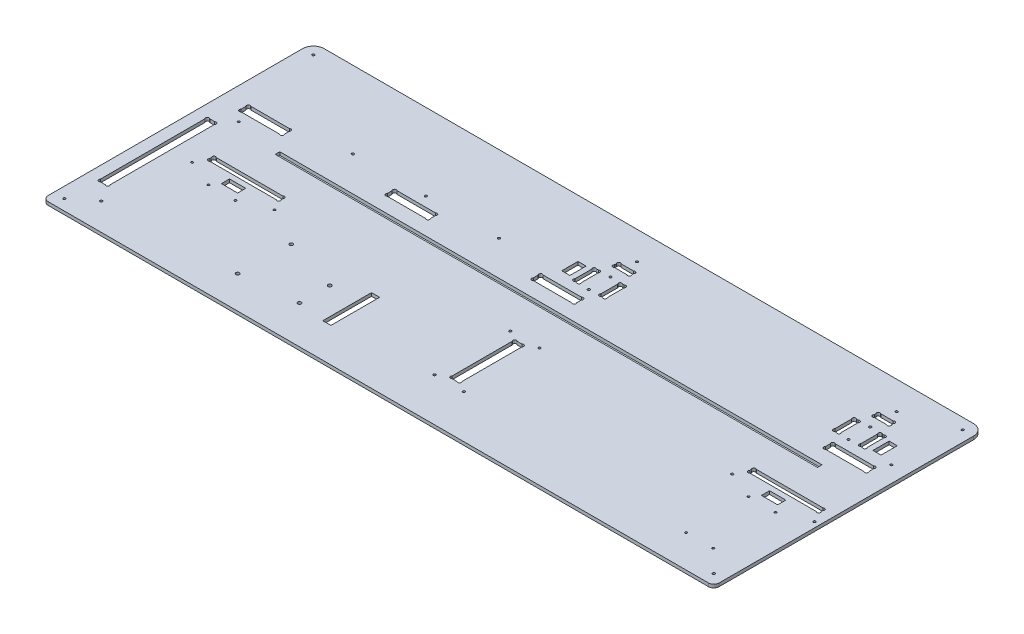
from build123d import *

# Parameters (mm, degrees)
ESQUISSE1_R             = 1.1
EXTRUSION1_DEPTH        = 3
ESQUISSE2_W             = 501
ESQUISSE2_H             = 4.2
ENL_V_MAT_EXTRU_1_DEPTH = 4
ESQUISSE3_R             = 1.1
ENL_V_MAT_EXTRU_2_DEPTH = 4
CONG_1_R                = 5
ESQUISSE4_R             = 1.1
ENL_V_MAT_EXTRU_3_DEPTH = 4
ESQUISSE5_R             = 1.59
ENL_V_MAT_EXTRU_4_DEPTH = 4
ESQUISSE6_W             = 15
ESQUISSE6_H             = 7.5
ESQUISSE6_W_2           = 7.5
ESQUISSE6_H_2           = 15
ESQUISSE6_H_3           = 45
ENL_V_MAT_EXTRU_5_DEPTH = 4
ESQUISSE7_R             = 1
ENL_V_MAT_EXTRU_6_DEPTH = 4
ESQUISSE8_R             = 1.1
ENL_V_MAT_EXTRU_7_DEPTH = 4


with BuildPart() as part:
    # Esquisse1 → Extrusion1 (new body)
    with BuildSketch(Plane(origin=(0, 0, 0), x_dir=(1, 0, 0), z_dir=(0, 1, 0))):
        with BuildLine():
            Line((10, 250), (610, 250))
            ThreePointArc((610, 250), (617.071067812, 247.071067812), (620, 240))
            Line((620, 240), (620, 0))
            Line((620, 0), (0, 0))
            Line((0, 0), (0, 240))
            ThreePointArc((0, 240), (2.928932188, 247.071067812), (10, 250))
        make_face()
        with Locations(Location((539, 98, 0), (0, 0, 270))):  # turned: the seam where the file's is
            Circle(ESQUISSE1_R, mode=Mode.SUBTRACT)
        with Locations(Location((615, 98, 0), (0, 0, 270))):  # turned: the seam where the file's is
            Circle(ESQUISSE1_R, mode=Mode.SUBTRACT)
        with BuildLine():
            Line((317, 211.2627417), (317, 212.7372583))
            ThreePointArc((317, 212.7372583), (317, 215), (319.2627417, 215))
            Line((319.2627417, 215), (330.7372583, 215))
            ThreePointArc((330.7372583, 215), (333, 215), (333, 212.7372583))
            Line((333, 212.7372583), (333, 211.2627417))
            ThreePointArc((333, 211.2627417), (333, 209), (330.737258301, 209))
            Line((330.737258301, 209), (319.262741699, 209))
            ThreePointArc((319.262741699, 209), (316.999999999, 209.000000001), (317, 211.2627417))
        make_face(mode=Mode.SUBTRACT)
        with BuildLine():
            Line((312.262741699, 179.5), (313.737258301, 179.5))
            ThreePointArc((313.737258301, 179.5), (316.000000001, 179.500000001), (316, 181.762741701))
            Line((316, 181.762741701), (316, 197.237258299))
            ThreePointArc((316, 197.237258299), (316.000000001, 199.499999999), (313.737258301, 199.5))
            Line((313.737258301, 199.5), (312.262741699, 199.5))
            ThreePointArc((312.262741699, 199.5), (309.999999999, 199.499999999), (310, 197.237258299))
            Line((310, 197.237258299), (310, 181.762741701))
            ThreePointArc((310, 181.762741701), (309.999999999, 179.500000001), (312.262741699, 179.5))
        make_face(mode=Mode.SUBTRACT)
        with BuildLine():
            Line((334, 181.762741701), (334, 197.2372583))
            ThreePointArc((334, 197.2372583), (334, 199.5), (336.2627417, 199.5))
            Line((336.2627417, 199.5), (337.7372583, 199.5))
            ThreePointArc((337.7372583, 199.5), (340, 199.5), (340, 197.2372583))
            Line((340, 197.2372583), (340, 181.762741701))
            ThreePointArc((340, 181.762741701), (340.000000001, 179.500000001), (337.737258301, 179.5))
            Line((337.737258301, 179.5), (336.262741699, 179.5))
            ThreePointArc((336.262741699, 179.5), (333.999999999, 179.500000001), (334, 181.762741701))
        make_face(mode=Mode.SUBTRACT)
        with BuildLine():
            Line((552.2627417, 179.5), (553.7372583, 179.5))
            ThreePointArc((553.7372583, 179.5), (556, 179.5), (556, 181.7627417))
            Line((556, 181.7627417), (556, 197.2372583))
            ThreePointArc((556, 197.2372583), (556, 199.5), (553.7372583, 199.5))
            Line((553.7372583, 199.5), (552.2627417, 199.5))
            ThreePointArc((552.2627417, 199.5), (550, 199.5), (550, 197.2372583))
            Line((550, 197.2372583), (550, 181.7627417))
            ThreePointArc((550, 181.7627417), (550, 179.5), (552.2627417, 179.5))
        make_face(mode=Mode.SUBTRACT)
        with BuildLine():
            Line((574, 181.7627417), (574, 197.2372583))
            ThreePointArc((574, 197.2372583), (574, 199.5), (576.2627417, 199.5))
            Line((576.2627417, 199.5), (577.7372583, 199.5))
            ThreePointArc((577.7372583, 199.5), (580, 199.5), (580, 197.2372583))
            Line((580, 197.2372583), (580, 181.7627417))
            ThreePointArc((580, 181.7627417), (580, 179.5), (577.7372583, 179.5))
            Line((577.7372583, 179.5), (576.2627417, 179.5))
            ThreePointArc((576.2627417, 179.5), (574, 179.5), (574, 181.7627417))
        make_face(mode=Mode.SUBTRACT)
        with BuildLine():
            Line((559.2627417, 209), (570.7372583, 209))
            ThreePointArc((570.7372583, 209), (573, 209), (573, 211.2627417))
            Line((573, 211.2627417), (573, 212.7372583))
            ThreePointArc((573, 212.7372583), (573, 215), (570.7372583, 215))
            Line((570.7372583, 215), (559.2627417, 215))
            ThreePointArc((559.2627417, 215), (557, 215), (557, 212.7372583))
            Line((557, 212.7372583), (557, 211.2627417))
            ThreePointArc((557, 211.2627417), (557, 209), (559.2627417, 209))
        make_face(mode=Mode.SUBTRACT)
        with BuildLine():
            Line((560, 167.7372583), (560, 163.2627417))
            ThreePointArc((560, 163.2627417), (560, 161), (562.2627417, 161))
            Line((562.2627417, 161), (597.7372583, 161))
            ThreePointArc((597.7372583, 161), (600, 161), (600, 163.2627417))
            Line((600, 163.2627417), (600, 167.7372583))
            ThreePointArc((600, 167.7372583), (600, 170), (597.7372583, 170))
            Line((597.7372583, 170), (562.2627417, 170))
            ThreePointArc((562.2627417, 170), (560, 170), (560, 167.7372583))
        make_face(mode=Mode.SUBTRACT)
        with BuildLine():
            Line((292.2627417, 161), (327.7372583, 161))
            ThreePointArc((327.7372583, 161), (330, 161), (330, 163.2627417))
            Line((330, 163.2627417), (330, 167.7372583))
            ThreePointArc((330, 167.7372583), (330, 170), (327.7372583, 170))
            Line((327.7372583, 170), (292.2627417, 170))
            ThreePointArc((292.2627417, 170), (290, 170), (290, 167.7372583))
            Line((290, 167.7372583), (290, 163.2627417))
            ThreePointArc((290, 163.2627417), (290, 161), (292.2627417, 161))
        make_face(mode=Mode.SUBTRACT)
        with BuildLine():
            Line((20, 167.7372583), (20, 163.2627417))
            ThreePointArc((20, 163.2627417), (20, 161), (22.2627417, 161))
            Line((22.2627417, 161), (57.7372583, 161))
            ThreePointArc((57.7372583, 161), (60, 161), (60, 163.2627417))
            Line((60, 163.2627417), (60, 167.7372583))
            ThreePointArc((60, 167.7372583), (60, 170), (57.7372583, 170))
            Line((57.7372583, 170), (22.2627417, 170))
            ThreePointArc((22.2627417, 170), (20, 170), (20, 167.7372583))
        make_face(mode=Mode.SUBTRACT)
        with BuildLine():
            Line((155, 167.7372583), (155, 163.2627417))
            ThreePointArc((155, 163.2627417), (155, 161), (157.2627417, 161))
            Line((157.2627417, 161), (192.7372583, 161))
            ThreePointArc((192.7372583, 161), (195, 161), (195, 163.2627417))
            Line((195, 163.2627417), (195, 167.7372583))
            ThreePointArc((195, 167.7372583), (195, 170), (192.7372583, 170))
            Line((192.7372583, 170), (157.2627417, 170))
            ThreePointArc((157.2627417, 170), (155, 170), (155, 167.7372583))
        make_face(mode=Mode.SUBTRACT)
        with BuildLine():
            Line((13.2627417, 40), (17.7372583, 40))
            ThreePointArc((17.7372583, 40), (20, 40), (20, 42.2627417))
            Line((20, 42.2627417), (20, 138.7372583))
            ThreePointArc((20, 138.7372583), (20, 141), (17.7372583, 141))
            Line((17.7372583, 141), (13.2627417, 141))
            ThreePointArc((13.2627417, 141), (11, 141), (11, 138.7372583))
            Line((11, 138.7372583), (11, 42.2627417))
            ThreePointArc((11, 42.2627417), (11, 40), (13.2627417, 40))
        make_face(mode=Mode.SUBTRACT)
        with BuildLine():
            Line((337.7372583, 45), (333.2627417, 45))
            ThreePointArc((333.2627417, 45), (331, 45), (331, 47.2627417))
            Line((331, 47.2627417), (331, 102.7372583))
            ThreePointArc((331, 102.7372583), (331, 105), (333.2627417, 105))
            Line((333.2627417, 105), (337.7372583, 105))
            ThreePointArc((337.7372583, 105), (340, 105), (340, 102.7372583))
            Line((340, 102.7372583), (340, 47.2627417))
            ThreePointArc((340, 47.2627417), (340, 45), (337.7372583, 45))
        make_face(mode=Mode.SUBTRACT)
        with BuildLine():
            Line((610, 109.2627417), (610, 110.7372583))
            ThreePointArc((610, 110.7372583), (610, 113), (607.7372583, 113))
            Line((607.7372583, 113), (546.2627417, 113))
            ThreePointArc((546.2627417, 113), (544, 113), (544, 110.7372583))
            Line((544, 110.7372583), (544, 109.2627417))
            ThreePointArc((544, 109.2627417), (544, 107), (546.2627417, 107))
            Line((546.2627417, 107), (607.7372583, 107))
            ThreePointArc((607.7372583, 107), (610, 107), (610, 109.2627417))
        make_face(mode=Mode.SUBTRACT)
        with BuildLine():
            Line((108.7372583, 113), (47.2627417, 113))
            ThreePointArc((47.2627417, 113), (45, 113), (45, 110.7372583))
            Line((45, 110.7372583), (45, 109.2627417))
            ThreePointArc((45, 109.2627417), (45, 107), (47.2627417, 107))
            Line((47.2627417, 107), (108.7372583, 107))
            ThreePointArc((108.7372583, 107), (111, 107), (111, 109.2627417))
            Line((111, 109.2627417), (111, 110.7372583))
            ThreePointArc((111, 110.7372583), (111, 113), (108.7372583, 113))
        make_face(mode=Mode.SUBTRACT)
    extrude(amount=EXTRUSION1_DEPTH)

    # Esquisse2 → Enlèv. mat.-Extru.1 (cut, through all)
    with BuildSketch(Plane(origin=(0, 3, 0), x_dir=(-1, 0, 0), z_dir=(0, 1, 0))):
        with Locations((-322.5, -144.9)):
            Rectangle(ESQUISSE2_W, ESQUISSE2_H)
    extrude(amount=-ENL_V_MAT_EXTRU_1_DEPTH, mode=Mode.SUBTRACT)

    # Esquisse3 → Enlèv. mat.-Extru.2 (cut, through all)
    with BuildSketch(Plane(origin=(0, 3, 0), x_dir=(1, 0, 0), z_dir=(0, 1, 0))):
        with Locations(Location((565, 179.5, 0), (0, 0, 270))):  # turned: the seam where the file's is
            Circle(ESQUISSE3_R)
        with Locations(Location((565, 199.5, 0), (0, 0, 270))):  # turned: the seam where the file's is
            Circle(ESQUISSE3_R)
        with Locations(Location((325, 179.5, 0), (0, 0, 270))):  # turned: the seam where the file's is
            Circle(ESQUISSE3_R)
        with Locations(Location((325, 199.5, 0), (0, 0, 270))):  # turned: the seam where the file's is
            Circle(ESQUISSE3_R)
    extrude(amount=-ENL_V_MAT_EXTRU_2_DEPTH, mode=Mode.SUBTRACT)

    # Congé1
    cong_1_edges = [part.edges().sort_by_distance(p)[0] for p in [
        (620, 1.5, 0),
        (0, 1.5, 0),
    ]]
    fillet(cong_1_edges, radius=CONG_1_R)

    # Esquisse4 → Enlèv. mat.-Extru.3 (cut, through all)
    with BuildSketch(Plane.XZ):
        with Locations(Location((10, -10, 0), (0, 0, 270))):  # turned: the seam where the file's is
            Circle(ESQUISSE4_R)
        with Locations(Location((610, -10, 0), (0, 0, 270))):  # turned: the seam where the file's is
            Circle(ESQUISSE4_R)
        with Locations(Location((610, -240, 0), (0, 0, 270))):  # turned: the seam where the file's is
            Circle(ESQUISSE4_R)
        with Locations(Location((10, -240, 0), (0, 0, 270))):  # turned: the seam where the file's is
            Circle(ESQUISSE4_R)
    extrude(amount=-ENL_V_MAT_EXTRU_3_DEPTH, mode=Mode.SUBTRACT)

    # Esquisse5 → Enlèv. mat.-Extru.4 (cut, through all)
    with BuildSketch(Plane(origin=(0, 3, 0), x_dir=(1, 0, 0), z_dir=(0, 1, 0))):
        with Locations(Location((151.27, 78.26, 0), (0, 0, 270))):  # turned: the seam where the file's is
            Circle(ESQUISSE5_R)
        with Locations(Location((150, 30, 0), (0, 0, 270))):  # turned: the seam where the file's is
            Circle(ESQUISSE5_R)
        with Locations(Location((202.07, 63.02, 0), (0, 0, 270))):  # turned: the seam where the file's is
            Circle(ESQUISSE5_R)
        with Locations(Location((202.07, 35.08, 0), (0, 0, 270))):  # turned: the seam where the file's is
            Circle(ESQUISSE5_R)
    extrude(amount=-ENL_V_MAT_EXTRU_4_DEPTH, mode=Mode.SUBTRACT)

    # Esquisse6 → Enlèv. mat.-Extru.5 (cut, through all)
    with BuildSketch(Plane(origin=(0, 3, 0), x_dir=(1, 0, 0), z_dir=(0, 1, 0))):
        with Locations((577, 98.25)):
            Rectangle(ESQUISSE6_W, ESQUISSE6_H)
        with Locations((588.75, 189.5)):
            Rectangle(ESQUISSE6_W_2, ESQUISSE6_H_2)
        with Locations((301.25, 189.5)):
            Rectangle(ESQUISSE6_W_2, ESQUISSE6_H_2)
        with Locations((230.82, 54.13)):
            Rectangle(ESQUISSE6_W_2, ESQUISSE6_H_3)
        with Locations((78, 98.25)):
            Rectangle(ESQUISSE6_W, ESQUISSE6_H)
    extrude(amount=-ENL_V_MAT_EXTRU_5_DEPTH, mode=Mode.SUBTRACT)

    # Esquisse7 → Enlèv. mat.-Extru.6 (cut, through all)
    with BuildSketch(Plane(origin=(0, 3, 0), x_dir=(1, 0, 0), z_dir=(0, 1, 0))):
        with Locations(Location((589.5, 87.5, 0), (0, 0, 270))):  # turned: the seam where the file's is
            Circle(ESQUISSE7_R)
        with Locations(Location((564.5, 87.5, 0), (0, 0, 270))):  # turned: the seam where the file's is
            Circle(ESQUISSE7_R)
        with Locations(Location((65.5, 87.5, 0), (0, 0, 270))):  # turned: the seam where the file's is
            Circle(ESQUISSE7_R)
        with Locations(Location((90.5, 87.5, 0), (0, 0, 270))):  # turned: the seam where the file's is
            Circle(ESQUISSE7_R)
        with Locations(Location((116, 98, 0), (0, 0, 270))):  # turned: the seam where the file's is
            Circle(ESQUISSE7_R)
        with Locations(Location((40, 98, 0), (0, 0, 270))):  # turned: the seam where the file's is
            Circle(ESQUISSE7_R)
        with Locations(Location((564.5, 30, 0), (0, 0, 270))):  # turned: the seam where the file's is
            Circle(ESQUISSE7_R)
        with Locations(Location((589.5, 30, 0), (0, 0, 270))):  # turned: the seam where the file's is
            Circle(ESQUISSE7_R)
    extrude(amount=-ENL_V_MAT_EXTRU_6_DEPTH, mode=Mode.SUBTRACT)

    # Esquisse8 → Enlèv. mat.-Extru.7 (cut, through all)
    with BuildSketch(Plane(origin=(0, 3, 0), x_dir=(1, 0, 0), z_dir=(0, 1, 0))):
        with Locations(Location((29, 25, 0), (0, 0, 270))):  # turned: the seam where the file's is
            Circle(ESQUISSE8_R)
        with Locations(Location((29, 152, 0), (0, 0, 270))):  # turned: the seam where the file's is
            Circle(ESQUISSE8_R)
        with Locations(Location((107.5, 179, 0), (0, 0, 270))):  # turned: the seam where the file's is
            Circle(ESQUISSE8_R)
        with Locations(Location((242.5, 179, 0), (0, 0, 270))):  # turned: the seam where the file's is
            Circle(ESQUISSE8_R)
        with Locations(Location((175, 179, 0), (0, 0, 270))):  # turned: the seam where the file's is
            Circle(ESQUISSE8_R)
        with Locations(Location((325, 224, 0), (0, 0, 270))):  # turned: the seam where the file's is
            Circle(ESQUISSE8_R)
        with Locations(Location((565, 224, 0), (0, 0, 270))):  # turned: the seam where the file's is
            Circle(ESQUISSE8_R)
        with Locations(Location((605, 179, 0), (0, 0, 270))):  # turned: the seam where the file's is
            Circle(ESQUISSE8_R)
        with Locations(Location((322, 40, 0), (0, 0, 270))):  # turned: the seam where the file's is
            Circle(ESQUISSE8_R)
        with Locations(Location((322, 110, 0), (0, 0, 270))):  # turned: the seam where the file's is
            Circle(ESQUISSE8_R)
        with Locations(Location((349, 110, 0), (0, 0, 270))):  # turned: the seam where the file's is
            Circle(ESQUISSE8_R)
        with Locations(Location((349, 40, 0), (0, 0, 270))):  # turned: the seam where the file's is
            Circle(ESQUISSE8_R)
    extrude(amount=-ENL_V_MAT_EXTRU_7_DEPTH, mode=Mode.SUBTRACT)


solid = part.part
